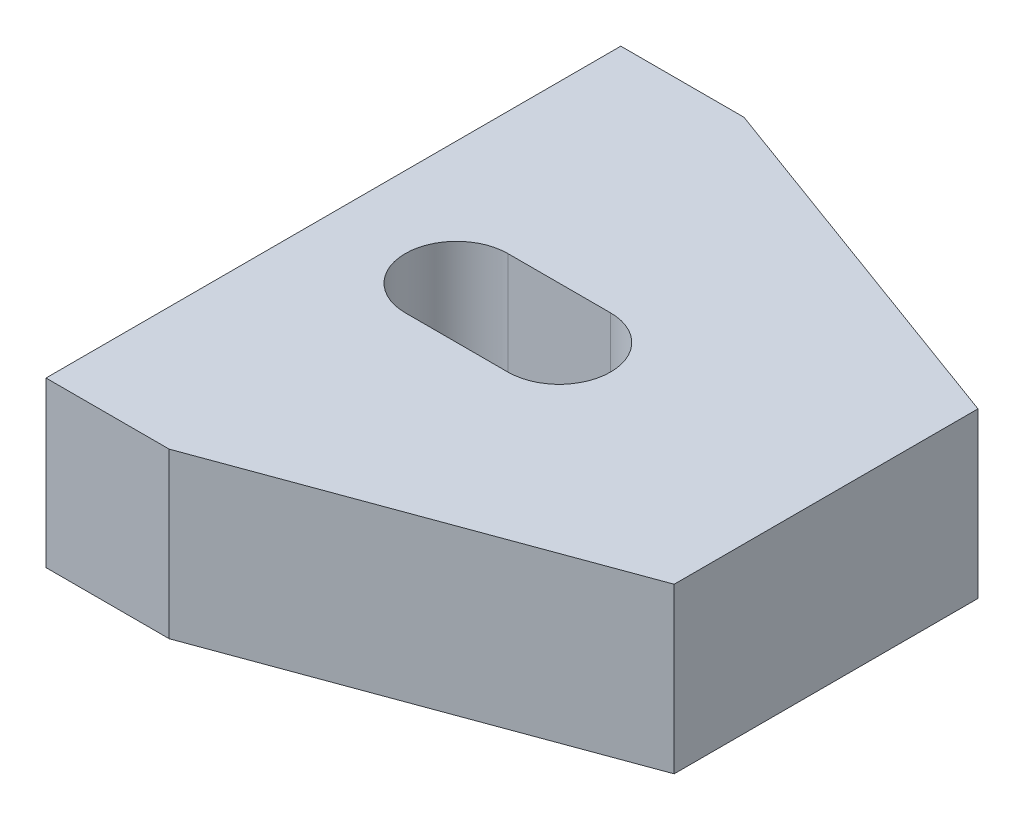
from build123d import *

# Parameters (mm, degrees)
BOSS_EXTRUDE1_DEPTH = 5.08


with BuildPart() as part:
    # Sketch1 → Boss-Extrude1 (new body)
    with BuildSketch(Plane(origin=(0, 0, 0), x_dir=(1, 0, 0), z_dir=(0, 1, 0))):
        Polygon((-15.24, 8.89), (-15.24, -8.89), (-11.43, -8.89), (0, -4.699), (0, 4.699), (-11.43, 8.89), align=None)
        with BuildLine():
            Line((-11.43, 1.5875), (-8.255, 1.5875))
            ThreePointArc((-8.255, 1.5875), (-6.6675, 0), (-8.255, -1.5875))
            Line((-8.255, -1.5875), (-11.43, -1.5875))
            ThreePointArc((-11.43, -1.5875), (-13.0175, 0), (-11.43, 1.5875))
        make_face(mode=Mode.SUBTRACT)
    extrude(amount=BOSS_EXTRUDE1_DEPTH)


solid = part.part
